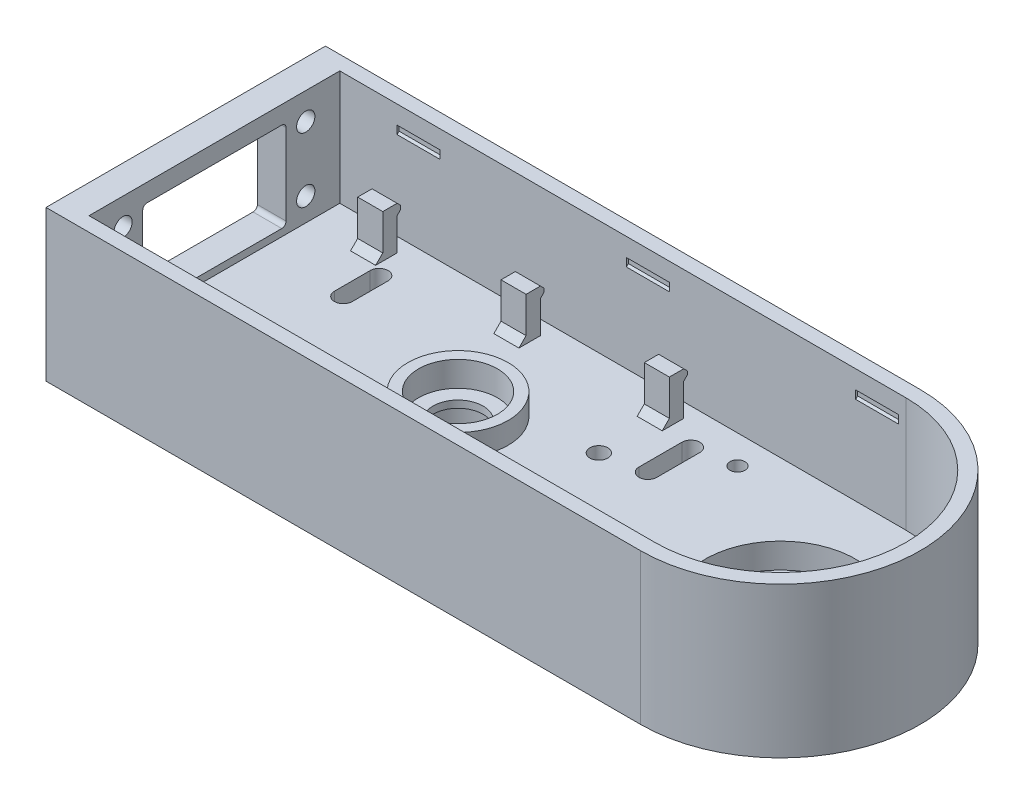
from build123d import *

# Parameters (mm, degrees)
BOSS_EXTRUDE1_DEPTH        = 10
BOSS_EXTRUDE2_DEPTH        = 32
CUT_EXTRUDE1_REACH         = 207
SKETCH3_R                  = 2.55
SKETCH3_W                  = 40
SKETCH3_H                  = 25
FILLET1_R                  = 1.2
SKETCH4_R                  = 7
SKETCH4_R_2                = 17.5
CUT_EXTRUDE2_DEPTH         = 11
SKETCH5_R                  = 21
CUT_EXTRUDE3_DEPTH         = 7
SKETCH6_R                  = 14
SKETCH6_R_2                = 11
BOSS_EXTRUDE3_DEPTH        = 6
CUT_EXTRUDE4_DEPTH         = 11
SKETCH8_R                  = 11
CUT_EXTRUDE5_DEPTH         = 7
SKETCH9_R                  = 2.1
SKETCH9_R_2                = 2.5
SKETCH9_R_3                = 1.6
CUT_EXTRUDE6_DEPTH         = 11
BOSS_EXTRUDE4_DEPTH        = 7
CHAMFER1_SIZE              = 2
LPATTERN1_COUNT            = 3
LPATTERN1_PITCH            = 40
CHAMFER1_OF_LPATTERN1_SIZE = 2
CUT_EXTRUDE7_DEPTH         = 12
LPATTERN2_COUNT            = 3
LPATTERN2_PITCH            = 64
MIRROR1_COPY_1_DEPTH       = 12
MIRROR1_COPY_2_DEPTH       = 12
CUT_REVOLVE1_ANGLE         = 20
SKETCH13_R                 = 11
CUT_EXTRUDE8_DEPTH         = 1


with BuildPart() as part:
    # Sketch1 → Boss-Extrude1 (new body)
    with BuildSketch(Plane(origin=(0, 0, 0), x_dir=(1, 0, 0), z_dir=(0, 1, 0))):
        with BuildLine():
            Line((0, 39), (-166, 39))
            Line((-166, 39), (-166, -39))
            Line((-166, -39), (0, -39))
            ThreePointArc((0, -39), (39, 0), (0, 39))
        make_face()
    extrude(amount=BOSS_EXTRUDE1_DEPTH)

    # Sketch2 → Boss-Extrude2 (add)
    with BuildSketch(Plane(origin=(0, 10, 0), x_dir=(1, 0, 0), z_dir=(0, 1, 0))):
        with BuildLine():
            Line((0, 39), (-166, 39))
            Line((-166, 39), (-166, -39))
            Line((-166, -39), (0, -39))
            ThreePointArc((0, -39), (39, 0), (0, 39))
        make_face()
        with BuildLine():
            Line((0, 35), (-158, 35))
            Line((-158, 35), (-158, -35))
            Line((-158, -35), (0, -35))
            ThreePointArc((0, -35), (35, 0), (0, 35))
        make_face(mode=Mode.SUBTRACT)
    extrude(amount=BOSS_EXTRUDE2_DEPTH)

    # Sketch3 → Cut-Extrude1 (cut, up to next)
    with BuildSketch(Plane.ZY.offset(166), mode=Mode.PRIVATE) as cut_extrude1_sk1:
        with Locations((-25.5, 34.5)):
            Circle(SKETCH3_R)
    cut_extrude1_tool1 = extrude(cut_extrude1_sk1.sketch, amount=-CUT_EXTRUDE1_REACH, mode=Mode.PRIVATE) & part.part
    add(cut_extrude1_tool1.solids().sort_by_distance((-166, 34.5, -25.5))[0], mode=Mode.SUBTRACT)
    # Sketch3 → Cut-Extrude1 (cut, up to next)
    with BuildSketch(Plane.ZY.offset(166), mode=Mode.PRIVATE) as cut_extrude1_sk2:
        with Locations((-25.5, 16.5)):
            Circle(SKETCH3_R)
    cut_extrude1_tool2 = extrude(cut_extrude1_sk2.sketch, amount=-CUT_EXTRUDE1_REACH, mode=Mode.PRIVATE) & part.part
    add(cut_extrude1_tool2.solids().sort_by_distance((-166, 16.5, -25.5))[0], mode=Mode.SUBTRACT)
    # Sketch3 → Cut-Extrude1 (cut, up to next)
    with BuildSketch(Plane.ZY.offset(166), mode=Mode.PRIVATE) as cut_extrude1_sk3:
        with Locations((25.5, 16.5)):
            Circle(SKETCH3_R)
    cut_extrude1_tool3 = extrude(cut_extrude1_sk3.sketch, amount=-CUT_EXTRUDE1_REACH, mode=Mode.PRIVATE) & part.part
    add(cut_extrude1_tool3.solids().sort_by_distance((-166, 16.5, 25.5))[0], mode=Mode.SUBTRACT)
    # Sketch3 → Cut-Extrude1 (cut, up to next)
    with BuildSketch(Plane.ZY.offset(166), mode=Mode.PRIVATE) as cut_extrude1_sk4:
        with Locations((25.5, 34.5)):
            Circle(SKETCH3_R)
    cut_extrude1_tool4 = extrude(cut_extrude1_sk4.sketch, amount=-CUT_EXTRUDE1_REACH, mode=Mode.PRIVATE) & part.part
    add(cut_extrude1_tool4.solids().sort_by_distance((-166, 34.5, 25.5))[0], mode=Mode.SUBTRACT)
    # Sketch3 → Cut-Extrude1 (cut, up to next)
    with BuildSketch(Plane.ZY.offset(166), mode=Mode.PRIVATE) as cut_extrude1_sk5:
        with Locations((0, 24.5)):
            Rectangle(SKETCH3_W, SKETCH3_H)
    cut_extrude1_tool5 = extrude(cut_extrude1_sk5.sketch, amount=-CUT_EXTRUDE1_REACH, mode=Mode.PRIVATE) & part.part
    add(cut_extrude1_tool5.solids().sort_by_distance((-166, 24.5, 0))[0], mode=Mode.SUBTRACT)

    # Fillet1
    fillet1_edges = [part.edges().sort_by_distance(p)[0] for p in [
        (-162, 37, -20),
        (-162, 12, -20),
        (-162, 12, 20),
        (-162, 37, 20),
    ]]
    fillet(fillet1_edges, radius=FILLET1_R)

    # Sketch4 → Cut-Extrude2 (cut, through all)
    with BuildSketch(Plane(origin=(0, 10, 0), x_dir=(1, 0, 0), z_dir=(0, 1, 0))):
        with Locations((-90, 0)):
            Circle(SKETCH4_R)
        Circle(SKETCH4_R_2)
    extrude(amount=-CUT_EXTRUDE2_DEPTH, mode=Mode.SUBTRACT)

    # Sketch5 → Cut-Extrude3 (cut)
    with BuildSketch(Plane(origin=(0, 10, 0), x_dir=(1, 0, 0), z_dir=(0, 1, 0))):
        Circle(SKETCH5_R)
    extrude(amount=-CUT_EXTRUDE3_DEPTH, mode=Mode.SUBTRACT)

    # Sketch6 → Boss-Extrude3 (add)
    with BuildSketch(Plane(origin=(0, 10, 0), x_dir=(1, 0, 0), z_dir=(0, 1, 0))):
        with Locations((-90, 0)):
            Circle(SKETCH6_R)
        with Locations((-90, 0)):
            Circle(SKETCH6_R_2, mode=Mode.SUBTRACT)
    extrude(amount=BOSS_EXTRUDE3_DEPTH)

    # Sketch7 → Cut-Extrude4 (cut, through all)
    with BuildSketch(Plane(origin=(0, 10, 0), x_dir=(1, 0, 0), z_dir=(0, 1, 0))):
        with BuildLine():
            Line((-132.5, 23), (-132.5, 13))
            ThreePointArc((-132.5, 13), (-135, 10.5), (-137.5, 13))
            Line((-137.5, 13), (-137.5, 23))
            ThreePointArc((-137.5, 23), (-135, 25.5), (-132.5, 23))
        make_face()
        with BuildLine():
            Line((-132.5, -13), (-132.5, -23))
            ThreePointArc((-132.5, -23), (-135, -25.5), (-137.5, -23))
            Line((-137.5, -23), (-137.5, -13))
            ThreePointArc((-137.5, -13), (-135, -10.5), (-132.5, -13))
        make_face()
        with BuildLine():
            Line((-47.5, 25), (-47.5, 13))
            ThreePointArc((-47.5, 13), (-50, 10.5), (-52.5, 13))
            Line((-52.5, 13), (-52.5, 25))
            ThreePointArc((-52.5, 25), (-50, 27.5), (-47.5, 25))
        make_face()
        with BuildLine():
            Line((-47.5, -21), (-47.5, -25))
            ThreePointArc((-47.5, -25), (-50, -27.5), (-52.5, -25))
            Line((-52.5, -25), (-52.5, -21))
            ThreePointArc((-52.5, -21), (-50, -18.5), (-47.5, -21))
        make_face()
    extrude(amount=-CUT_EXTRUDE4_DEPTH, mode=Mode.SUBTRACT)

    # Sketch8 → Cut-Extrude5 (cut)
    with BuildSketch(Plane.XZ):
        with Locations((-90, 0)):
            Circle(SKETCH8_R)
    extrude(amount=-CUT_EXTRUDE5_DEPTH, mode=Mode.SUBTRACT)

    # Sketch9 → Cut-Extrude6 (cut, through all)
    with BuildSketch(Plane(origin=(0, 10, 0), x_dir=(1, 0, 0), z_dir=(0, 1, 0))):
        with Locations((-39, 27)):
            Circle(SKETCH9_R)
        with Locations((-61.5, 10.809700388)):
            Circle(SKETCH9_R_2)
        with Locations((-58, -9.459979846)):
            Circle(SKETCH9_R_3)
        with Locations((-49.611997868, -5)):
            Circle(SKETCH9_R_3)
    extrude(amount=-CUT_EXTRUDE6_DEPTH, mode=Mode.SUBTRACT)

    # Sketch10 → Boss-Extrude4 (add)
    with BuildSketch(Plane(origin=(-145, 0, 0), x_dir=(0, 0, -1), z_dir=(1, 0, 0))):
        Polygon((27, 10), (31, 10), (31, 19), (32, 20), (32, 21), (31, 22), (27, 22), align=None)
    boss_extrude4 = extrude(amount=BOSS_EXTRUDE4_DEPTH)

    # Chamfer1
    chamfer1_edges = [part.edges().sort_by_distance(p)[0] for p in [
        (-141.5, 10, -27),
    ]]
    chamfer(chamfer1_edges, length=CHAMFER1_SIZE)

    # LPattern1: Boss-Extrude4 ×3
    with Locations(*[(i * LPATTERN1_PITCH, 0, 0) for i in range(1, LPATTERN1_COUNT)]):
        add(boss_extrude4)

    # Chamfer1 of LPattern1
    chamfer1_of_lpattern1_edges = [part.edges().sort_by_distance(p)[0] for p in [
        (-101.5, 10, -27),
        (-61.5, 10, -27),
    ]]
    chamfer(chamfer1_of_lpattern1_edges, length=CHAMFER1_OF_LPATTERN1_SIZE)

    # Sketch11 → Cut-Extrude7 (cut)
    with BuildSketch(Plane.ZY.offset(142)):
        Polygon((-35, 34.6), (-35, 36.9), (-35.55, 36.35), (-35.55, 35.15), align=None)
    cut_extrude7 = extrude(amount=-CUT_EXTRUDE7_DEPTH, mode=Mode.SUBTRACT)

    # LPattern2: Cut-Extrude7 ×3
    with Locations(*[(i * LPATTERN2_PITCH, 0, 0) for i in range(1, LPATTERN2_COUNT)]):
        add(cut_extrude7, mode=Mode.SUBTRACT)

    # Mirror1: Cut-Extrude7 across plane
    add(cut_extrude7.mirror(Plane.XY), mode=Mode.SUBTRACT)

    # Mirror1 copy 1 sketch → Mirror1 copy 1 (cut)
    with BuildSketch(Plane(origin=(-78, 0, 0), x_dir=(0, 0, -1), z_dir=(-1, 0, 0))):
        Polygon((-35, -34.6), (-35, -36.9), (-35.55, -36.35), (-35.55, -35.15), align=None)
    extrude(amount=-MIRROR1_COPY_1_DEPTH, mode=Mode.SUBTRACT)

    # Mirror1 copy 2 sketch → Mirror1 copy 2 (cut)
    with BuildSketch(Plane(origin=(-14, 0, 0), x_dir=(0, 0, -1), z_dir=(-1, 0, 0))):
        Polygon((-35, -34.6), (-35, -36.9), (-35.55, -36.35), (-35.55, -35.15), align=None)
    extrude(amount=-MIRROR1_COPY_2_DEPTH, mode=Mode.SUBTRACT)

    # Sketch12 → Cut-Revolve1 (revolve, symmetric, cut)
    with BuildSketch(Plane.XY) as cut_revolve1_sk:
        Polygon((35.55, 36.35), (35, 36.9), (35, 34.6), (35.55, 35.15), align=None)
    revolve(axis=Axis((0, 42, 0), (0, -1, 0)), revolution_arc=CUT_REVOLVE1_ANGLE / 2, mode=Mode.SUBTRACT)
    revolve(cut_revolve1_sk.sketch, axis=Axis((0, 42, 0), (0, 1, 0)), revolution_arc=CUT_REVOLVE1_ANGLE / 2, mode=Mode.SUBTRACT)

    # Sketch13 → Cut-Extrude8 (cut)
    with BuildSketch(Plane(origin=(0, 10, 0), x_dir=(1, 0, 0), z_dir=(0, 1, 0))):
        with Locations((-90, 0)):
            Circle(SKETCH13_R)
    extrude(amount=-CUT_EXTRUDE8_DEPTH, mode=Mode.SUBTRACT)


solid = part.part
